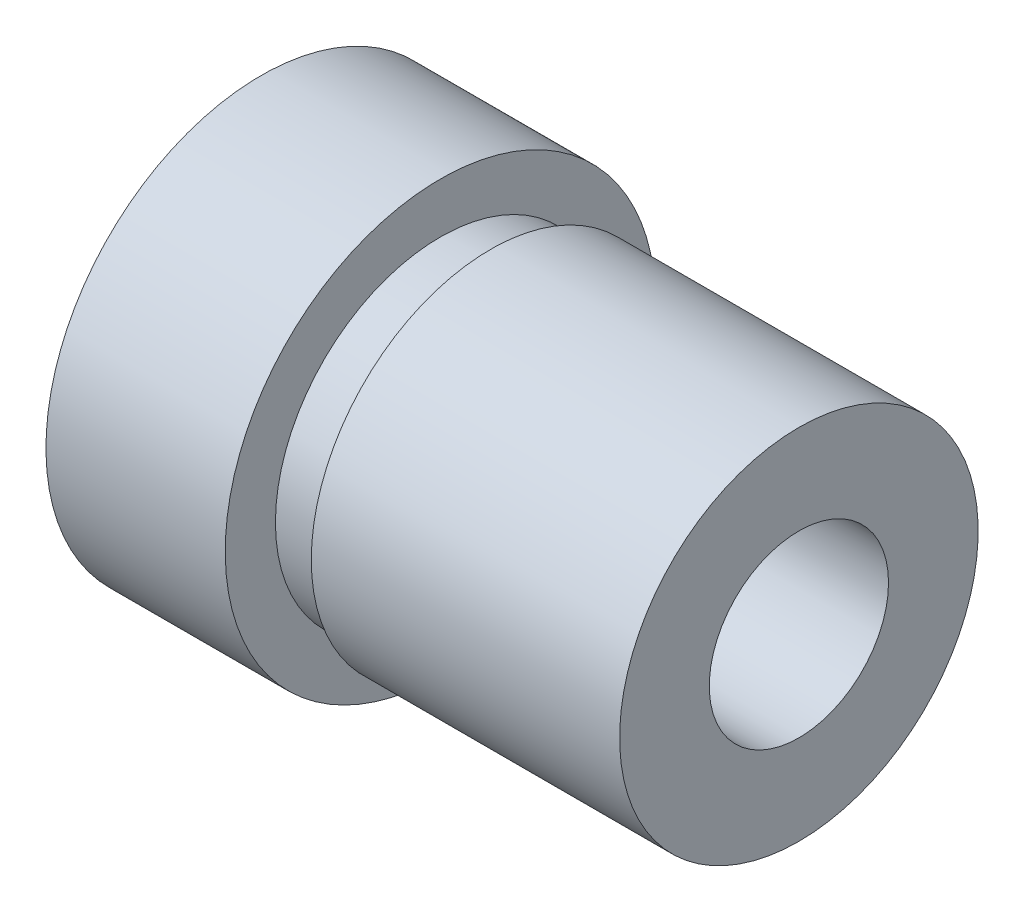
from build123d import *

# Parameters (mm, degrees)
TROU_TARAUD_M31_D = 2.5
SKETCH4_W         = 0.7
SKETCH4_H         = 0.7


with BuildPart() as part:
    # Sketch1 → Revolve1 (revolve)
    with BuildSketch(Plane.XY):
        Polygon((-3.75, 0), (-3.75, 3), (-1.25, 3), (-1.25, 2.5), (3.75, 2.5), (3.75, 0), align=None)
    revolve(axis=Axis((0, 0, 0), (1, 0, 0)))

    # Trou taraudé M31 (through all)
    with Locations(Plane(origin=(3.75, 0, 0), x_dir=(0, 0, -1), z_dir=(1, 0, 0))):
        with Locations((0, 0)):
            Hole(TROU_TARAUD_M31_D / 2)

    # Sketch4 → Cut-Revolve1 (revolve, cut)
    with BuildSketch(Plane.XY):
        with Locations((-0.9, 2.65)):
            Rectangle(SKETCH4_W, SKETCH4_H)
    revolve(axis=Axis((-0.090346983, 0, 0), (1, 0, 0)), mode=Mode.SUBTRACT)


solid = part.part
